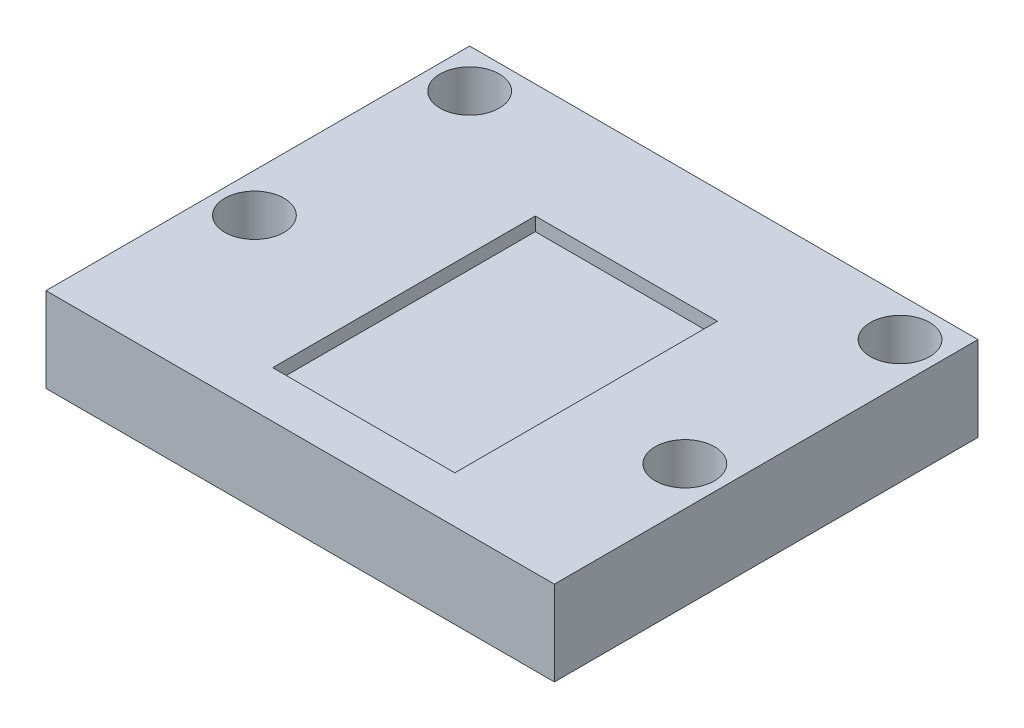
from build123d import *

# Parameters (mm, degrees)
SKETCH2_W           = 60
SKETCH2_H           = 50
BOSS_EXTRUDE1_DEPTH = 10
SKETCH1_R           = 3.5
CUT_EXTRUDE1_DEPTH  = 10
SKETCH3_W           = 21.5
SKETCH3_H           = 31
CUT_EXTRUDE2_DEPTH  = 1.6


with BuildPart() as part:
    # Sketch2 → Boss-Extrude1 (new body)
    with BuildSketch(Plane(origin=(0, 0, 0), x_dir=(1, 0, 0), z_dir=(0, 1, 0))):
        with Locations((30, 25)):
            Rectangle(SKETCH2_W, SKETCH2_H)
    extrude(amount=BOSS_EXTRUDE1_DEPTH)

    # Sketch1 → Cut-Extrude1 (cut)
    with BuildSketch(Plane(origin=(0, 10, 0), x_dir=(1, 0, 0), z_dir=(0, 1, 0))):
        with BuildLine():
            Line((4.6, 48.9), (4.6, 45.4))
            Line((4.6, 45.4), (1.1, 45.4))
            ThreePointArc((1.1, 45.4), (4.6, 41.9), (8.1, 45.4))
            ThreePointArc((8.1, 45.4), (7.074873734, 47.874873734), (4.6, 48.9))
        make_face()
        with BuildLine():
            Line((1.1, 45.4), (4.6, 45.4))
            Line((4.6, 45.4), (4.6, 48.9))
            ThreePointArc((4.6, 48.9), (2.125126266, 47.874873734), (1.1, 45.4))
        make_face()
        with Locations((55.4, 45.4)):
            Circle(SKETCH1_R)
        with Locations((4.6, 20)):
            Circle(SKETCH1_R)
        with Locations((55.4, 20)):
            Circle(SKETCH1_R)
    extrude(amount=-CUT_EXTRUDE1_DEPTH, mode=Mode.SUBTRACT)

    # Sketch3 → Cut-Extrude2 (cut)
    with BuildSketch(Plane(origin=(0, 10, 0), x_dir=(1, 0, 0), z_dir=(0, 1, 0))):
        with Locations((32, 21)):
            Rectangle(SKETCH3_W, SKETCH3_H)
    extrude(amount=-CUT_EXTRUDE2_DEPTH, mode=Mode.SUBTRACT)


solid = part.part
